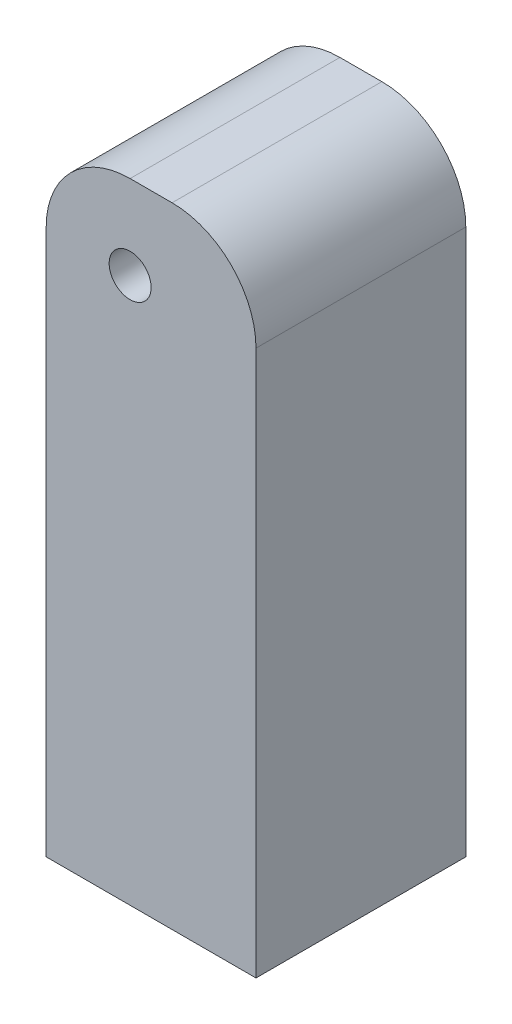
from build123d import *

# Parameters (mm, degrees)
SKETCH1_R           = 5
BOSS_EXTRUDE1_DEPTH = 25
SKETCH2_R           = 10
CUT_EXTRUDE1_DEPTH  = 50
SCALE1_SCALE        = 0.3


with BuildPart() as part:
    # Sketch1 → Boss-Extrude1 (new body, symmetric)
    with BuildSketch(Plane.XY):
        with BuildLine():
            Line((150, 25), (160, 25))
            ThreePointArc((160, 25), (174.142135624, 19.142135624), (180, 5))
            Line((180, 5), (180, -125))
            Line((180, -125), (130, -125))
            Line((130, -125), (130, 5))
            ThreePointArc((130, 5), (135.857864376, 19.142135624), (150, 25))
        make_face()
        with Locations((150, 5)):
            Circle(SKETCH1_R, mode=Mode.SUBTRACT)
    extrude(amount=BOSS_EXTRUDE1_DEPTH, both=True)

    # Sketch2 → Cut-Extrude1 (cut)
    with BuildSketch(Plane.XZ.offset(125)):
        with Locations((155, 0)):
            Circle(SKETCH2_R)
    extrude(amount=-CUT_EXTRUDE1_DEPTH, mode=Mode.SUBTRACT)


with BuildPart() as part_1:
    # Scale1: scaled about (155.056620621, -50.103937956, 0)
    add(part.part.scale(SCALE1_SCALE).moved(Location((108.539634435, -35.072756569, 0))))


solid = part_1.part
